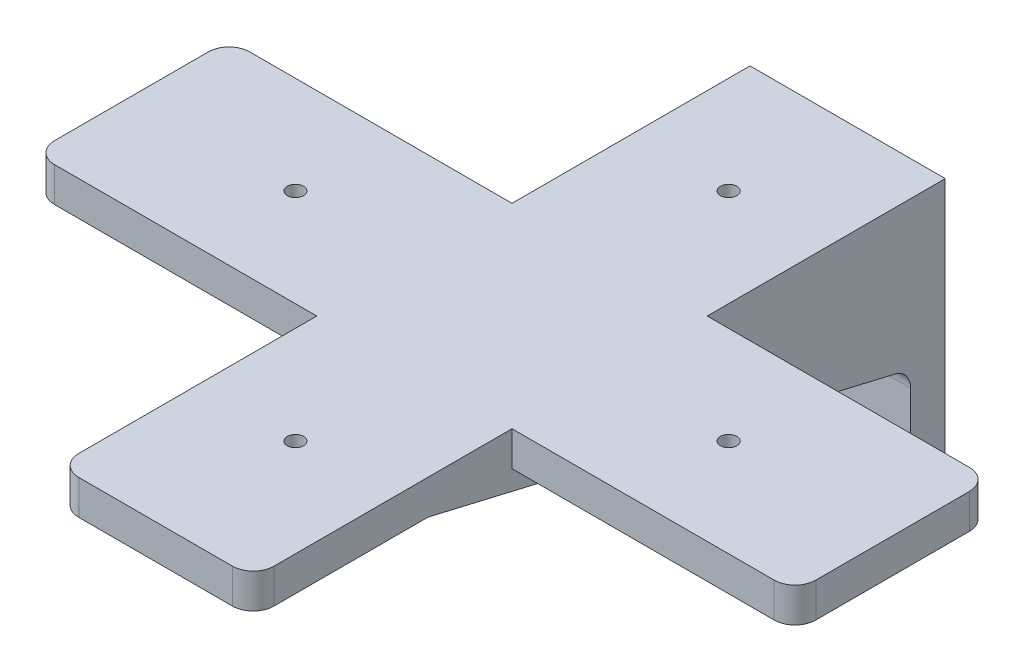
from build123d import *

# Parameters (mm, degrees)
SKETCH1_W           = 35.8267
SKETCH1_H           = 54.2417
BOSS_EXTRUDE1_DEPTH = 6.35
SKETCH2_W           = 35.8267
SKETCH2_H           = 127
BOSS_EXTRUDE2_DEPTH = 6.35
BOSS_EXTRUDE3_DEPTH = 5.08
FILLET1_R           = 3.81
BOSS_EXTRUDE4_DEPTH = 6.35
SKETCH7_R           = 1.4986
CUT_EXTRUDE2_DEPTH  = 6.35


with BuildPart() as part:
    # Sketch1 → Boss-Extrude1 (new body)
    with BuildSketch(Plane.XY):
        Rectangle(SKETCH1_W, SKETCH1_H)
    extrude(amount=BOSS_EXTRUDE1_DEPTH)

    # Sketch2 → Boss-Extrude2 (add)
    with BuildSketch(Plane(origin=(0, 27.12085, 0), x_dir=(1, 0, 0), z_dir=(0, 1, 0))):
        with Locations((0, -63.5)):
            Rectangle(SKETCH2_W, SKETCH2_H)
    extrude(amount=-BOSS_EXTRUDE2_DEPTH)

    # Sketch4 → Boss-Extrude3 (add)
    with BuildSketch(Plane(origin=(17.91335, 0, 0), x_dir=(0, 0, -1), z_dir=(1, 0, 0))):
        Polygon((-6.35, 0), (-94.906446238, 20.77085), (-6.35, 20.77085), align=None)
    boss_extrude3 = extrude(amount=-BOSS_EXTRUDE3_DEPTH)

    # Mirror1: Boss-Extrude3 across plane
    add(boss_extrude3.mirror(Plane(origin=(0, 0, 0), x_dir=(0, 0, 1), z_dir=(1, 0, 0))))

    # Fillet1
    fillet1_edges = [part.edges().sort_by_distance(p)[0] for p in [
        (-17.91335, 23.94585, 127),
        (17.91335, 23.94585, 127),
        (15.37335, 0, 6.35),
        (15.37335, 20.77085, 94.906446238),
        (-15.37335, 0, 6.35),
        (-15.37335, 20.77085, 94.906446238),
        (17.91335, -27.12085, 3.175),
        (-17.91335, -27.12085, 3.175),
    ]]
    fillet(fillet1_edges, radius=FILLET1_R)

    # Sketch6 → Boss-Extrude4 (add)
    with BuildSketch(Plane(origin=(0, 27.12085, 0), x_dir=(1, 0, 0), z_dir=(0, 1, 0))):
        with BuildLine():
            Line((-66.04, -79.50835), (66.04, -79.50835))
            ThreePointArc((66.04, -79.50835), (68.734076836, -78.392426836), (69.85, -75.69835))
            Line((69.85, -75.69835), (69.85, -47.49165))
            ThreePointArc((69.85, -47.49165), (68.734076836, -44.797573164), (66.04, -43.68165))
            Line((66.04, -43.68165), (-66.04, -43.68165))
            ThreePointArc((-66.04, -43.68165), (-68.734076836, -44.797573164), (-69.85, -47.49165))
            Line((-69.85, -47.49165), (-69.85, -75.69835))
            ThreePointArc((-69.85, -75.69835), (-68.734076836, -78.392426836), (-66.04, -79.50835))
        make_face()
    extrude(amount=-BOSS_EXTRUDE4_DEPTH)

    # Sketch7 → Cut-Extrude2 (cut)
    with BuildSketch(Plane(origin=(0, 27.12085, 0), x_dir=(1, 0, 0), z_dir=(0, 1, 0))):
        with Locations((0, -21.840825)):
            Circle(SKETCH7_R)
        with Locations((39.754175, -61.595)):
            Circle(SKETCH7_R)
        with Locations((0, -101.349175)):
            Circle(SKETCH7_R)
        with Locations((-39.754175, -61.595)):
            Circle(SKETCH7_R)
    extrude(amount=-CUT_EXTRUDE2_DEPTH, mode=Mode.SUBTRACT)


solid = part.part
